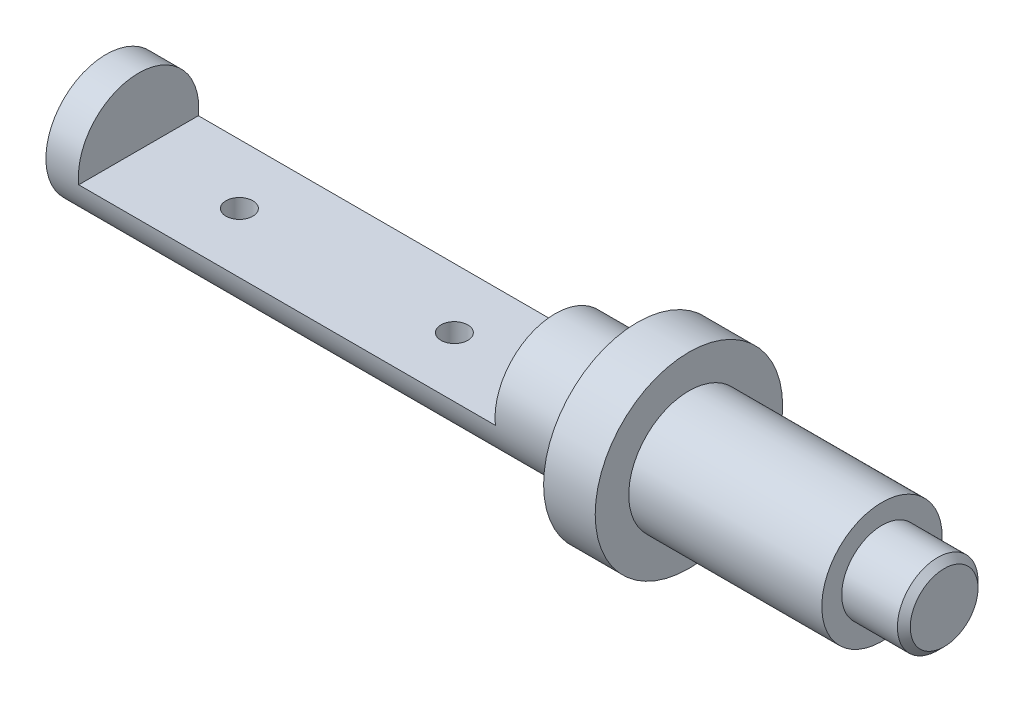
from build123d import *

# Parameters (mm, degrees)
SKETCH1_R           = 28
BOSS_EXTRUDE1_DEPTH = 247.1
SKETCH2_R           = 43.6
BOSS_EXTRUDE2_DEPTH = 24
SKETCH3_R           = 28
BOSS_EXTRUDE3_DEPTH = 89.8
SKETCH4_R           = 18.75
BOSS_EXTRUDE4_DEPTH = 28.9
CHAMFER1_SIZE       = 3
SKETCH5_W           = 193.8
SKETCH5_H           = 31.1
CUT_EXTRUDE1_DEPTH  = 54.45
CUT_EXTRUDE2_REACH  = 42.5
SKETCH6_R           = 6.25


with BuildPart() as part:
    # Sketch1 → Boss-Extrude1 (new body)
    with BuildSketch(Plane(origin=(0, 0, 0), x_dir=(0, 0, -1), z_dir=(1, 0, 0))):
        Circle(SKETCH1_R)
    extrude(amount=BOSS_EXTRUDE1_DEPTH)

    # Sketch2 → Boss-Extrude2 (add)
    with BuildSketch(Plane(origin=(247.1, 0, 0), x_dir=(0, 0, -1), z_dir=(1, 0, 0))):
        Circle(SKETCH2_R)
    extrude(amount=BOSS_EXTRUDE2_DEPTH)

    # Sketch3 → Boss-Extrude3 (add)
    with BuildSketch(Plane(origin=(271.1, 0, 0), x_dir=(0, 0, -1), z_dir=(1, 0, 0))):
        Circle(SKETCH3_R)
    extrude(amount=BOSS_EXTRUDE3_DEPTH)

    # Sketch4 → Boss-Extrude4 (add)
    with BuildSketch(Plane(origin=(360.9, 0, 0), x_dir=(0, 0, -1), z_dir=(1, 0, 0))):
        Circle(SKETCH4_R)
    extrude(amount=BOSS_EXTRUDE4_DEPTH)

    # Chamfer1
    chamfer1_edges = [part.edges().sort_by_distance(p)[0] for p in [
        (389.8, 0, 18.75),
    ]]
    chamfer(chamfer1_edges, length=CHAMFER1_SIZE)

    # Sketch5 → Cut-Extrude1 (cut, symmetric)
    with BuildSketch(Plane.XY):
        with Locations((112, 12.45)):
            Rectangle(SKETCH5_W, SKETCH5_H)
    extrude(amount=CUT_EXTRUDE1_DEPTH, both=True, mode=Mode.SUBTRACT)

    # Sketch6 → Cut-Extrude2 (cut, up to next)
    with BuildSketch(Plane(origin=(0, -3.1, 0), x_dir=(1, 0, 0), z_dir=(0, 1, 0)), mode=Mode.PRIVATE) as cut_extrude2_sk1:
        with Locations((62, 0)):
            Circle(SKETCH6_R)
    cut_extrude2_tool1 = extrude(cut_extrude2_sk1.sketch, amount=-CUT_EXTRUDE2_REACH, mode=Mode.PRIVATE) & part.part
    add(cut_extrude2_tool1.solids().sort_by_distance((62, -3.1, 0))[0], mode=Mode.SUBTRACT)
    # Sketch6 → Cut-Extrude2 (cut, up to next)
    with BuildSketch(Plane(origin=(0, -3.1, 0), x_dir=(1, 0, 0), z_dir=(0, 1, 0)), mode=Mode.PRIVATE) as cut_extrude2_sk2:
        with Locations((162, 0)):
            Circle(SKETCH6_R)
    cut_extrude2_tool2 = extrude(cut_extrude2_sk2.sketch, amount=-CUT_EXTRUDE2_REACH, mode=Mode.PRIVATE) & part.part
    add(cut_extrude2_tool2.solids().sort_by_distance((162, -3.1, 0))[0], mode=Mode.SUBTRACT)


solid = part.part
